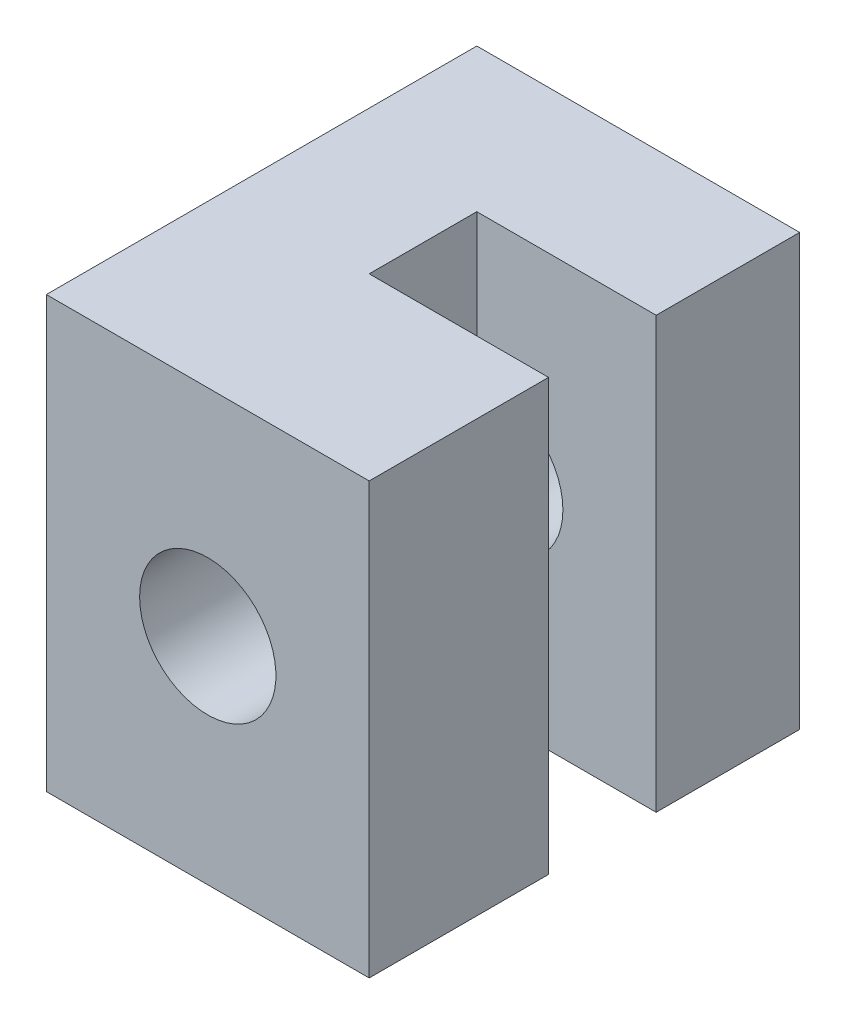
from build123d import *

# Parameters (mm, degrees)
SKETCH1_W           = 5
SKETCH1_H           = 5
BOSS_EXTRUDE2_DEPTH = 6
SKETCH2_R           = 1.9
CUT_EXTRUDE1_DEPTH  = 13


with BuildPart() as part:
    # Sketch1 → Boss-Extrude2 (new body, symmetric)
    with BuildSketch(Plane(origin=(0, 0, 0), x_dir=(1, 0, 0), z_dir=(0, 1, 0))):
        Polygon((-4.5, 6), (-4.5, -6), (-0.5, -6), (-0.5, -1), (-0.5, 2), (4.5, 2), (4.5, 6), align=None)
        with Locations((2, -3.5)):
            Rectangle(SKETCH1_W, SKETCH1_H)
    extrude(amount=BOSS_EXTRUDE2_DEPTH, both=True)

    # Sketch2 → Cut-Extrude1 (cut, through all)
    with BuildSketch(Plane(origin=(0, 0, -6), x_dir=(-1, 0, 0), z_dir=(0, 0, -1))):
        Circle(SKETCH2_R)
    extrude(amount=-CUT_EXTRUDE1_DEPTH, mode=Mode.SUBTRACT)


solid = part.part
